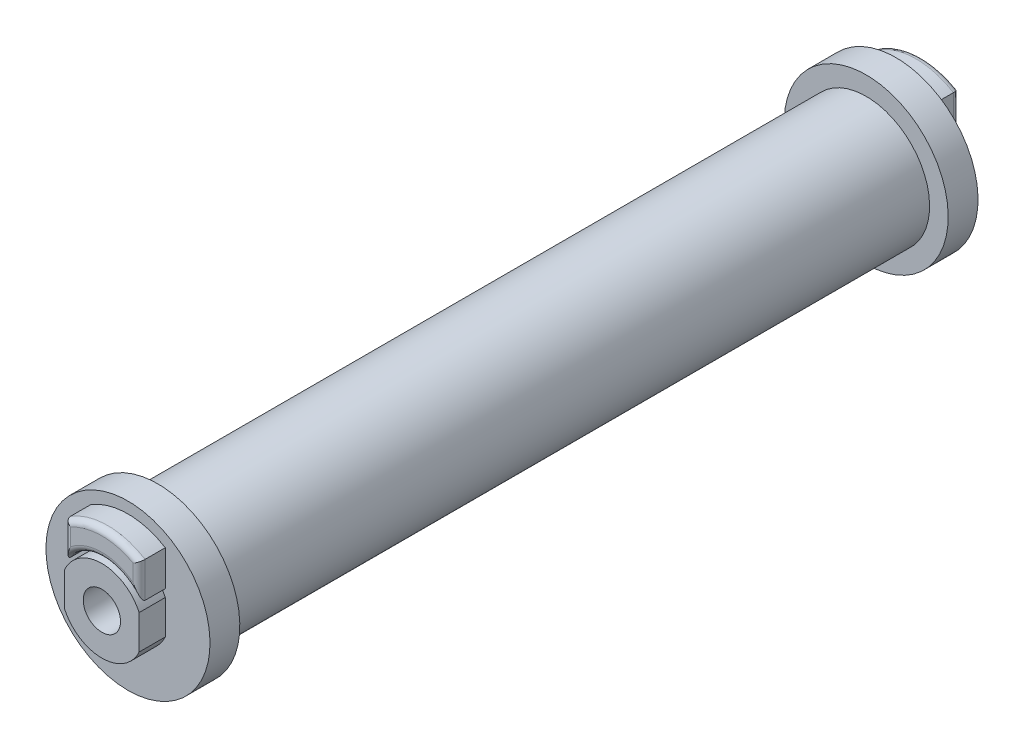
from build123d import *

# Parameters (mm, degrees)
CORTAR_EXTRUIR1_DEPTH = 3.5
REDONDEO1_R           = 0.8


with BuildPart() as part:
    # Croquis1 → Revolución1 (revolve)
    with BuildSketch(Plane(origin=(0, 0, 0), x_dir=(0, 0, -1), z_dir=(1, 0, 0))):
        Polygon((0, 2.5), (-55, 2.5), (-55, 5.5), (-51.5, 5.5), (-51.5, 6), (-55, 6), (-55, 9.5), (-51.5, 9.5), (-51.5, 11), (-47.5, 11), (-47.5, 8.5), (0, 8.5), align=None)
    revolve(axis=Axis((0, 0, 58.146951639), (0, 0, -1)))

    # Croquis2 → Cortar-Extruir1 (cut)
    with BuildSketch(Plane.XY.offset(55)):
        with BuildLine():
            Line((-5, 0), (-5, 8.077747211))
            ThreePointArc((-5, 8.077747211), (0, -9.5), (5, 8.077747211))
            Line((5, 8.077747211), (5, 0))
            Line((5, 0), (5, -2.291287847))
            ThreePointArc((5, -2.291287847), (0, -5.5), (-5, -2.291287847))
            Line((-5, -2.291287847), (-5, 0))
        make_face()
    extrude(amount=-CORTAR_EXTRUIR1_DEPTH, mode=Mode.SUBTRACT)

    # Redondeo1
    redondeo1_edges = [part.edges().sort_by_distance(p)[0] for p in [
        (0, 9.5, 55),
        (0, 6, 55),
        (5, 5.697186001, 55),
        (-5, 5.697186001, 55),
    ]]
    fillet(redondeo1_edges, radius=REDONDEO1_R)

    # Simetría1: part across plane


with BuildPart() as part_1:
    add(part.part)
    add(part.part.mirror(Plane.XY))


solid = part_1.part
